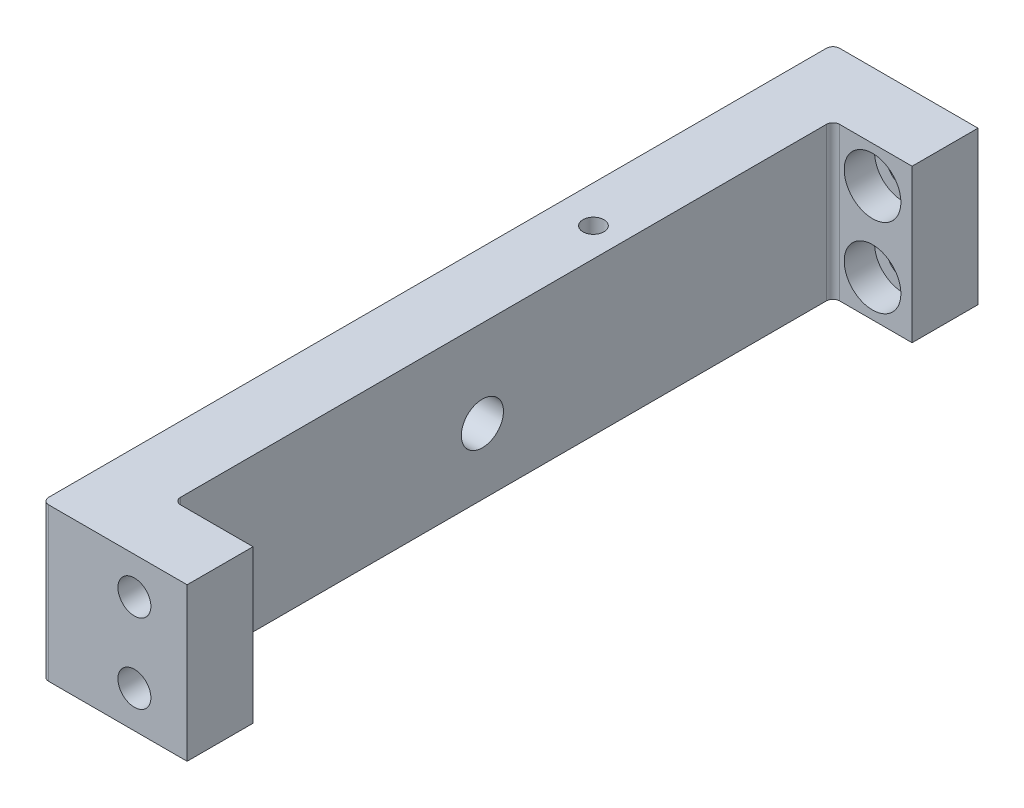
from build123d import *

# Parameters (mm, degrees)
SKETCH_1_W                  = 5
SKETCH_1_H                  = 11.6
EXTRUDE_1_DEPTH             = 30
SKETCH_2_W                  = 5
SKETCH_2_H                  = 11.6
EXTRUDE_2_DEPTH             = 6
HOLE_WIZARD_M3_1_D          = 2.5
HOLE_WIZARD_M3_1_DEPTH      = 7.5
HOLE_WIZARD_M3_1_TIP        = 0.751075774
HOLE_WIZARD_1_D             = 2.4
HOLE_WIZARD_1_DEPTH         = 7.5
HOLE_WIZARD_1_CBORE_D       = 4.3
HOLE_WIZARD_1_CBORE_DEPTH   = 2.3
HOLE_WIZARD_1_TIP           = 0.721032743
FILLET_1_R                  = 0.5
HOLE_WIZARD_3_2_3_2_1_D     = 3.2
HOLE_WIZARD_3_2_3_2_1_DEPTH = 5.2
HOLE_WIZARD_3_2_3_2_1_TIP   = 0.96137699
HOLE_WIZARD_M2_1_D          = 1.6
HOLE_WIZARD_M2_1_DEPTH      = 5.2
HOLE_WIZARD_M2_1_TIP        = 0.480688495


with BuildPart() as part:
    # 草图1 → 凸台-拉伸1 (new body, symmetric)
    with BuildSketch(Plane.XY):
        Rectangle(SKETCH_1_W, SKETCH_1_H)
    extrude(amount=EXTRUDE_1_DEPTH, both=True)

    # 草图2 → 凸台-拉伸2 (add)
    with BuildSketch(Plane(origin=(2.5, 0, 0), x_dir=(0, 0, -1), z_dir=(1, 0, 0))):
        with Locations((-27.5, 0)):
            Rectangle(SKETCH_2_W, SKETCH_2_H)
    extrude_2 = extrude(amount=EXTRUDE_2_DEPTH)

    # 镜向1: 凸台-拉伸2 across plane
    add(extrude_2.mirror(Plane.XY))

    # M3 螺纹孔1
    with Locations(Plane.XY.offset(30)):
        with Locations((4.5, -3), (4.5, 3)):
            Hole(HOLE_WIZARD_M3_1_D / 2, depth=HOLE_WIZARD_M3_1_DEPTH)
            with Locations((0, 0, -(HOLE_WIZARD_M3_1_DEPTH + HOLE_WIZARD_M3_1_TIP / 2))):  # 118° drill point
                Cone(0, HOLE_WIZARD_M3_1_D / 2, HOLE_WIZARD_M3_1_TIP, mode=Mode.SUBTRACT)

    # 打孔尺寸(%根据)内六角圆柱头螺钉的类型1
    with Locations(Plane.XY.offset(-25)):
        with Locations((5.5, -3), (5.5, 3)):
            CounterBoreHole(HOLE_WIZARD_1_D / 2, HOLE_WIZARD_1_CBORE_D / 2, HOLE_WIZARD_1_CBORE_DEPTH, depth=HOLE_WIZARD_1_DEPTH)
            with Locations((0, 0, -(HOLE_WIZARD_1_DEPTH + HOLE_WIZARD_1_TIP / 2))):  # 118° drill point
                Cone(0, HOLE_WIZARD_1_D / 2, HOLE_WIZARD_1_TIP, mode=Mode.SUBTRACT)

    # 圆角1
    fillet_1_edges = [part.edges().sort_by_distance(p)[0] for p in [
        (2.5, 0, 25),
        (2.5, 0, -25),
        (-2.5, 0, 30),
        (-2.5, 0, -30),
    ]]
    fillet(fillet_1_edges, radius=FILLET_1_R)

    # Ø3.2 (3.2) 直径孔1
    with Locations(Plane.ZY.offset(2.5)):
        with Locations((1.6, -0.8)):
            Hole(HOLE_WIZARD_3_2_3_2_1_D / 2, depth=HOLE_WIZARD_3_2_3_2_1_DEPTH)
            with Locations((0, 0, -(HOLE_WIZARD_3_2_3_2_1_DEPTH + HOLE_WIZARD_3_2_3_2_1_TIP / 2))):  # 118° drill point
                Cone(0, HOLE_WIZARD_3_2_3_2_1_D / 2, HOLE_WIZARD_3_2_3_2_1_TIP, mode=Mode.SUBTRACT)

    # M2 螺纹孔1
    with Locations(Plane(origin=(0, 5.8, 0), x_dir=(1, 0, 0), z_dir=(0, 1, 0))):
        with Locations((0.325, 9)):
            Hole(HOLE_WIZARD_M2_1_D / 2, depth=HOLE_WIZARD_M2_1_DEPTH)
            with Locations((0, 0, -(HOLE_WIZARD_M2_1_DEPTH + HOLE_WIZARD_M2_1_TIP / 2))):  # 118° drill point
                Cone(0, HOLE_WIZARD_M2_1_D / 2, HOLE_WIZARD_M2_1_TIP, mode=Mode.SUBTRACT)


solid = part.part
